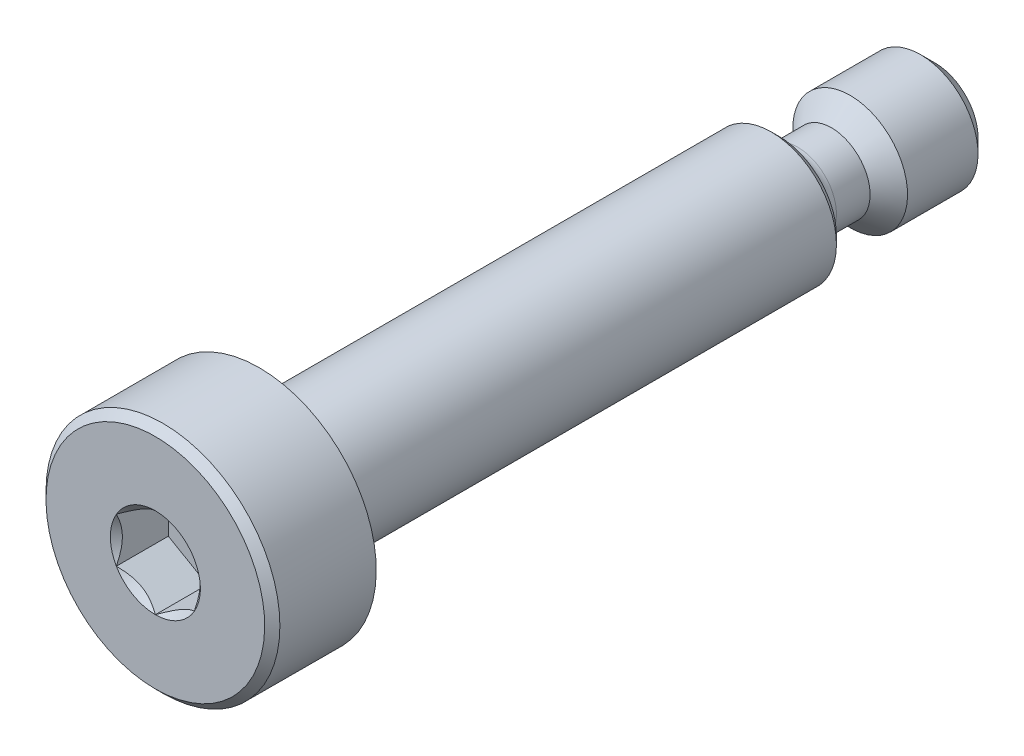
from build123d import *

# Parameters (mm, degrees)
CHAMFER1_SIZE      = 0.43815
CHAMFER2_SIZE      = 0.232171875
CUT_EXTRUDE2_DEPTH = 1.5875


with BuildPart() as part:
    # Sketch1 → Revolve1 (revolve)
    with BuildSketch(Plane(origin=(0, 0, 0), x_dir=(0, 0, -1), z_dir=(1, 0, 0))):
        Polygon((0, 3.571875), (3.175, 3.571875), (3.175, 1.984375), (19.05, 1.984375), (19.05, 1.7526), (23.8125, 1.7526), (23.8125, 0), (0, 0), align=None)
    revolve(axis=Axis((0, 0, -23.8125), (0, 0, 1)))

    # Sketch5 → Cut-Revolve1 (revolve, cut)
    with BuildSketch(Plane(origin=(0, 0, 0), x_dir=(0, 0, -1), z_dir=(1, 0, 0))):
        with BuildLine():
            Line((19.05, 1.984375), (21.453475, 1.984375))
            Line((21.453475, 1.984375), (20.6502, 1.1811))
            Line((20.6502, 1.1811), (19.6215, 1.1811))
            ThreePointArc((19.6215, 1.1811), (19.217388475, 1.348488475), (19.05, 1.7526))
            Line((19.05, 1.7526), (19.05, 1.984375))
        make_face()
    revolve(axis=Axis((0, 0, -23.8125), (0, 0, 1)), mode=Mode.SUBTRACT)

    # Chamfer1
    chamfer1_edges = [part.edges().sort_by_distance(p)[0] for p in [
        (0, -1.7526, -23.8125),
    ]]
    chamfer(chamfer1_edges, length=CHAMFER1_SIZE)

    # Chamfer2
    chamfer2_edges = [part.edges().sort_by_distance(p)[0] for p in [
        (0, -3.571875, 0),
        (0, -1.984375, -19.05),
    ]]
    chamfer(chamfer2_edges, length=CHAMFER2_SIZE)

    # Sketch8 → Cut-Extrude2 (cut)
    with BuildSketch(Plane.XY):
        Polygon((1.190625, 0.687407664), (0, 1.374815329), (-1.190625, 0.687407664), (-1.190625, -0.687407664), (0, -1.374815329), (1.190625, -0.687407664), align=None)
    extrude(amount=-CUT_EXTRUDE2_DEPTH, mode=Mode.SUBTRACT)

    # Cut-Extrude4 cone 1 section (through the dimple's axis) → Cut-Extrude4 (revolve, cut)
    with BuildSketch(Plane(origin=(0, 0, 0), x_dir=(0, -1, 0), z_dir=(1, 0, 0))):
        Polygon((0, 0), (1.374815329, 0), (0, 1.374815329), align=None)
    revolve(axis=Axis((0, 0, 0), (0, 0, -1)), mode=Mode.SUBTRACT)


solid = part.part
